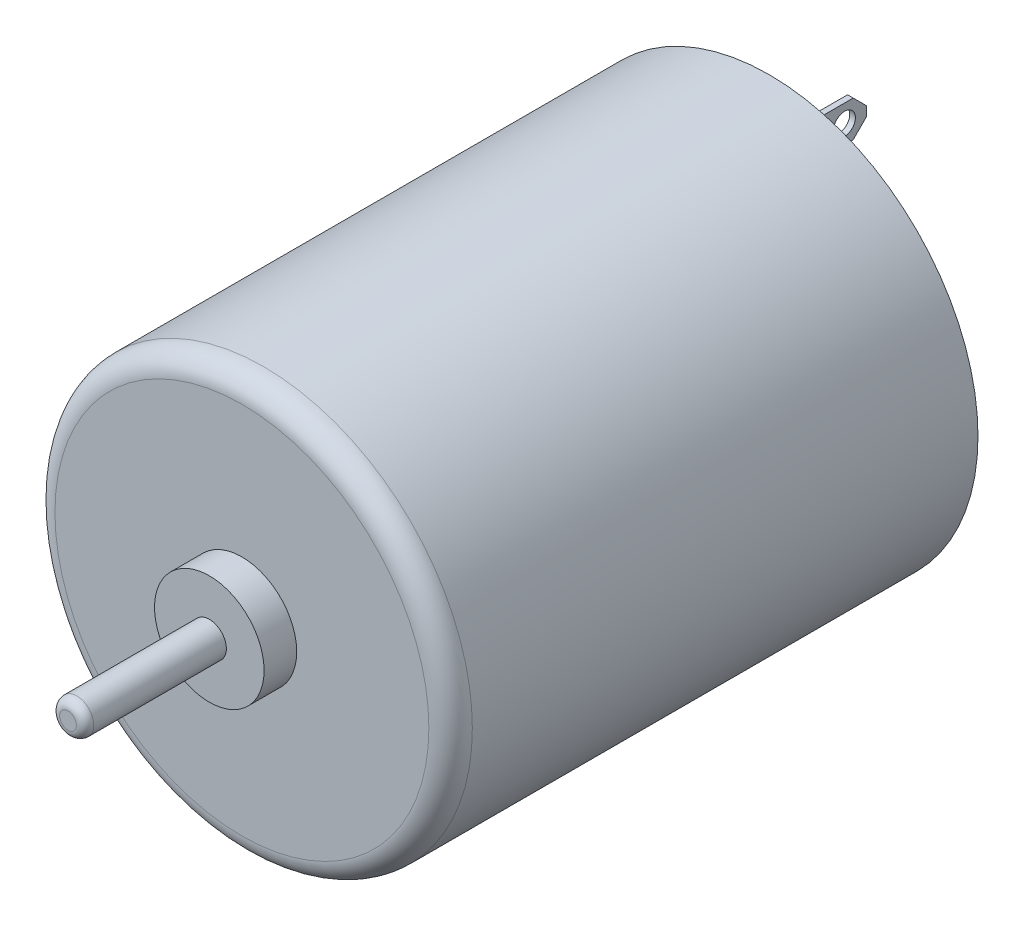
from build123d import *

# Parameters (mm, degrees)
SKETCH1_R           = 12.192
BOSS_EXTRUDE1_DEPTH = 30.8102
SKETCH2_R           = 0.99695
BOSS_EXTRUDE3_DEPTH = 10.16
SKETCH6_R           = 3.2004
BOSS_EXTRUDE4_DEPTH = 1.905
FILLET2_R           = 0.508
FILLET3_R           = 1.27
SKETCH7_R           = 11.7094
CUT_EXTRUDE1_DEPTH  = 1.016
SKETCH10_R          = 3.2258
BOSS_EXTRUDE5_DEPTH = 2.794
FILLET4_R           = 0.889
SKETCH11_W          = 0.3302
SKETCH11_H          = 2.1082
BOSS_EXTRUDE6_DEPTH = 5.08
SKETCH12_R          = 0.635
CUT_EXTRUDE2_DEPTH  = 0.3302
CIRPATTERN1_COUNT   = 2


with BuildPart() as part:
    # Sketch1 → Boss-Extrude1 (new body)
    with BuildSketch(Plane.XY):
        Circle(SKETCH1_R)
    extrude(amount=BOSS_EXTRUDE1_DEPTH)

    # Sketch2 → Boss-Extrude3 (add)
    with BuildSketch(Plane.XY.offset(30.8102)):
        Circle(SKETCH2_R)
    extrude(amount=BOSS_EXTRUDE3_DEPTH)

    # Sketch6 → Boss-Extrude4 (add)
    with BuildSketch(Plane.XY.offset(30.8102)):
        Circle(SKETCH6_R)
    extrude(amount=BOSS_EXTRUDE4_DEPTH)

    # Fillet2
    fillet2_edges = [part.edges().sort_by_distance(p)[0] for p in [
        (-0.99695, 0, 40.9702),
    ]]
    fillet(fillet2_edges, radius=FILLET2_R)

    # Fillet3
    fillet3_edges = [part.edges().sort_by_distance(p)[0] for p in [
        (-12.192, 0, 30.8102),
    ]]
    fillet(fillet3_edges, radius=FILLET3_R)

    # Sketch7 → Cut-Extrude1 (cut)
    with BuildSketch(Plane(origin=(0, 0, 0), x_dir=(-1, 0, 0), z_dir=(0, 0, -1))):
        Circle(SKETCH7_R)
    extrude(amount=-CUT_EXTRUDE1_DEPTH, mode=Mode.SUBTRACT)

    # Sketch10 → Boss-Extrude5 (add)
    with BuildSketch(Plane(origin=(0, 0, 1.016), x_dir=(-1, 0, 0), z_dir=(0, 0, -1))):
        Circle(SKETCH10_R)
    extrude(amount=BOSS_EXTRUDE5_DEPTH)

    # Fillet4
    fillet4_edges = [part.edges().sort_by_distance(p)[0] for p in [
        (3.2258, 0, -1.778),
    ]]
    fillet(fillet4_edges, radius=FILLET4_R)

    # Sketch11 → Boss-Extrude6 (add)
    with BuildSketch(Plane(origin=(0, 0, 1.016), x_dir=(-1, 0, 0), z_dir=(0, 0, -1))):
        with Locations((1.4351, -9.1059)):
            Rectangle(SKETCH11_W, SKETCH11_H)
    boss_extrude6 = extrude(amount=BOSS_EXTRUDE6_DEPTH)

    # Sketch12 → Cut-Extrude2 (cut)
    with BuildSketch(Plane(origin=(-1.27, 0, 0), x_dir=(0, 0, -1), z_dir=(1, 0, 0))):
        with Locations((2.794, -9.1059)):
            Circle(SKETCH12_R)
        Polygon((3.302, -8.0518), (4.064, -8.8138), (4.064, -8.0518), align=None)
        Polygon((4.064, -9.398), (3.302, -10.16), (4.064, -10.16), align=None)
    cut_extrude2 = extrude(amount=-CUT_EXTRUDE2_DEPTH, mode=Mode.SUBTRACT)

    # CirPattern1: Boss-Extrude6, Cut-Extrude2 ×2 about axis
    cirpattern1_axis = Axis((0, 0, 0), (0, 0, 1))
    for i in range(1, CIRPATTERN1_COUNT):
        add(boss_extrude6.rotate(cirpattern1_axis, i * 360 / CIRPATTERN1_COUNT))
        add(cut_extrude2.rotate(cirpattern1_axis, i * 360 / CIRPATTERN1_COUNT), mode=Mode.SUBTRACT)


solid = part.part
